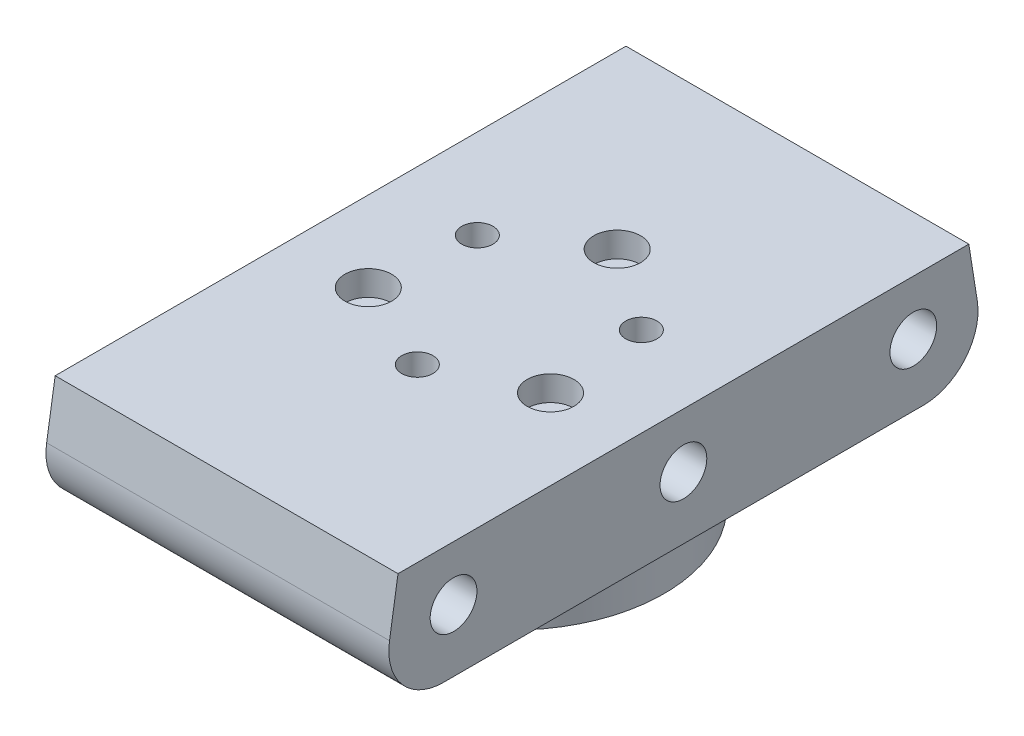
from build123d import *

# Parameters (mm, degrees)
SKETCH_1_R          = 19.5
SKETCH_1_R_2        = 2
SKETCH_1_R_3        = 1.5
EXTRUDE_1_DEPTH     = 6.8
SKETCH_2_W          = 44
SKETCH_2_H          = 78
EXTRUDE_2_DEPTH     = 70
SKETCH_3_R          = 3
CUT_EXTRUDE_1_DEPTH = 12
CUT_EXTRUDE_2_DEPTH = 33
SKETCH_6_R          = 3
CUT_EXTRUDE_3_DEPTH = 12
CHAMFER_1_SIZE      = 2
FILLET_1_R          = 7
SKETCH_7_R          = 2
SKETCH_7_R_2        = 1.5
CUT_EXTRUDE_4_DEPTH = 22.8
SKETCH_8_R          = 3
CUT_EXTRUDE_5_DEPTH = 3.2


with BuildPart() as part:
    # 草图1 → 凸台-拉伸1 (new body)
    with BuildSketch(Plane(origin=(0, 0, 0), x_dir=(1, 0, 0), z_dir=(0, 1, 0))):
        Circle(SKETCH_1_R)
        with Locations((10.522208656, 6.075)):
            Circle(SKETCH_1_R_2, mode=Mode.SUBTRACT)
        with Locations((-10.522208656, 6.075)):
            Circle(SKETCH_1_R_2, mode=Mode.SUBTRACT)
        with Locations((0, -12.15)):
            Circle(SKETCH_1_R_2, mode=Mode.SUBTRACT)
        with Locations((0, 13.5)):
            Circle(SKETCH_1_R_3, mode=Mode.SUBTRACT)
        with Locations((11.691342951, -6.75)):
            Circle(SKETCH_1_R_3, mode=Mode.SUBTRACT)
        with Locations((-11.691342951, -6.75)):
            Circle(SKETCH_1_R_3, mode=Mode.SUBTRACT)
    extrude(amount=EXTRUDE_1_DEPTH)

    # 草图2 → 凸台-拉伸2 (add)
    with BuildSketch(Plane(origin=(0, 6.8, 0), x_dir=(1, 0, 0), z_dir=(0, 1, 0))):
        Rectangle(SKETCH_2_W, SKETCH_2_H)
    extrude(amount=EXTRUDE_2_DEPTH)

    # 草图3 → 切除-拉伸1 (cut)
    with BuildSketch(Plane(origin=(22, 0, 0), x_dir=(0, 0, -1), z_dir=(1, 0, 0))):
        with Locations((0, 14.8)):
            Circle(SKETCH_3_R)
        with Locations((-29.5, 14.8)):
            Circle(SKETCH_3_R)
        with Locations((29.5, 14.8)):
            Circle(SKETCH_3_R)
        Polygon((-39, 6.8), (-36.626907991, 21.8), (36.626907991, 21.8), (39, 6.8), (44.081826142, 6.8), (44.081826142, 83.498576474), (-44.081826142, 83.498576474), (-44.081826142, 6.8), align=None)
    extrude(amount=-CUT_EXTRUDE_1_DEPTH, mode=Mode.SUBTRACT)

    # 草图5 → 切除-拉伸2 (cut, through all)
    with BuildSketch(Plane(origin=(10, 0, 0), x_dir=(0, 0, -1), z_dir=(1, 0, 0))):
        Polygon((-39, 6.8), (-36.626907991, 21.8), (36.626907991, 21.8), (39, 6.8), (39, 76.8), (-39, 76.8), align=None)
    extrude(amount=-CUT_EXTRUDE_2_DEPTH, mode=Mode.SUBTRACT)

    # 草图6 → 切除-拉伸3 (cut)
    with BuildSketch(Plane.ZY.offset(22)):
        with Locations((-29.5, 14.8)):
            Circle(SKETCH_6_R)
        with Locations((0, 14.8)):
            Circle(SKETCH_6_R)
        with Locations((29.5, 14.8)):
            Circle(SKETCH_6_R)
    extrude(amount=-CUT_EXTRUDE_3_DEPTH, mode=Mode.SUBTRACT)

    # 倒角1
    chamfer_1_edges = [part.edges().sort_by_distance(p)[0] for p in [
        (-19.5, 6.8, 0),
    ]]
    chamfer(chamfer_1_edges, length=CHAMFER_1_SIZE)

    # 圆角1
    fillet_1_edges = [part.edges().sort_by_distance(p)[0] for p in [
        (0, 6.8, -39),
        (0, 6.8, 39),
    ]]
    fillet(fillet_1_edges, radius=FILLET_1_R)

    # 草图7 → 切除-拉伸4 (cut, through all)
    with BuildSketch(Plane(origin=(0, 21.8, 0), x_dir=(1, 0, 0), z_dir=(0, 1, 0))):
        with Locations((10.522208656, 6.075)):
            Circle(SKETCH_7_R)
        with Locations((11.691342951, -6.75)):
            Circle(SKETCH_7_R_2)
        with Locations((0, -12.15)):
            Circle(SKETCH_7_R)
        with Locations((-11.691342951, -6.75)):
            Circle(SKETCH_7_R_2)
        with Locations((-10.522208656, 6.075)):
            Circle(SKETCH_7_R)
        with Locations((0, 13.5)):
            Circle(SKETCH_7_R_2)
    extrude(amount=-CUT_EXTRUDE_4_DEPTH, mode=Mode.SUBTRACT)

    # 草图8 → 切除-拉伸5 (cut)
    with BuildSketch(Plane(origin=(0, 21.8, 0), x_dir=(1, 0, 0), z_dir=(0, 1, 0))):
        with Locations((0, 13.5)):
            Circle(SKETCH_8_R)
        with Locations((11.691342951, -6.75)):
            Circle(SKETCH_8_R)
        with Locations((-11.691342951, -6.75)):
            Circle(SKETCH_8_R)
    extrude(amount=-CUT_EXTRUDE_5_DEPTH, mode=Mode.SUBTRACT)


solid = part.part
